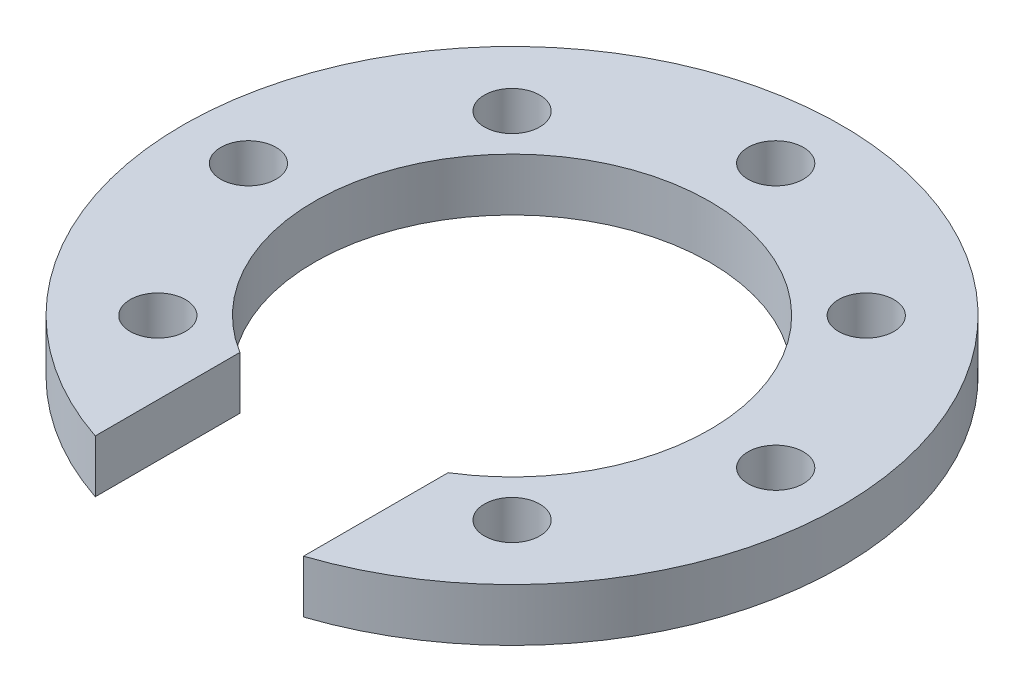
from build123d import *

# Parameters (mm, degrees)
SKETCH1_R           = 12.5
SKETCH1_R_2         = 7.5
BOSS_EXTRUDE1_DEPTH = 2
SKETCH2_R           = 1.05
CUT_EXTRUDE1_DEPTH  = 5
CIRPATTERN1_COUNT   = 3
CIRPATTERN1_ANGLE   = 180
SKETCH3_R           = 1.05
CUT_EXTRUDE2_DEPTH  = 2
SKETCH4_W           = 7.9
SKETCH4_H           = 11.346310676
CUT_EXTRUDE3_DEPTH  = 10


with BuildPart() as part:
    # Sketch1 → Boss-Extrude1 (new body)
    with BuildSketch(Plane(origin=(0, 0, 0), x_dir=(1, 0, 0), z_dir=(0, 1, 0))):
        Circle(SKETCH1_R)
        Circle(SKETCH1_R_2, mode=Mode.SUBTRACT)
    extrude(amount=BOSS_EXTRUDE1_DEPTH)

    # Sketch2 → Cut-Extrude1 (cut)
    with BuildSketch(Plane(origin=(0, 2, 0), x_dir=(1, 0, 0), z_dir=(0, 1, 0))):
        with Locations((10, 0)):
            Circle(SKETCH2_R)
    cut_extrude1 = extrude(amount=-CUT_EXTRUDE1_DEPTH, mode=Mode.SUBTRACT)

    # CirPattern1: Cut-Extrude1 ×3 about axis
    cirpattern1_axis = Axis((0, 0, 0), (0, 1, 0))
    for i in range(1, CIRPATTERN1_COUNT):
        add(cut_extrude1.rotate(cirpattern1_axis, i * CIRPATTERN1_ANGLE / (CIRPATTERN1_COUNT - 1)), mode=Mode.SUBTRACT)

    # Sketch3 → Cut-Extrude2 (cut)
    with BuildSketch(Plane(origin=(0, 2, 0), x_dir=(1, 0, 0), z_dir=(0, 1, 0))):
        with Locations((-6.71751442, 6.71751442)):
            Circle(SKETCH3_R)
        with Locations((6.71751442, 6.71751442)):
            Circle(SKETCH3_R)
        with Locations((6.71751442, -6.71751442)):
            Circle(SKETCH3_R)
        with Locations((-6.71751442, -6.71751442)):
            Circle(SKETCH3_R)
    extrude(amount=-CUT_EXTRUDE2_DEPTH, mode=Mode.SUBTRACT)

    # Sketch4 → Cut-Extrude3 (cut)
    with BuildSketch(Plane(origin=(0, 2, 0), x_dir=(1, 0, 0), z_dir=(0, 1, 0))):
        with Locations((0, -10.263253748)):
            Rectangle(SKETCH4_W, SKETCH4_H)
    extrude(amount=-CUT_EXTRUDE3_DEPTH, mode=Mode.SUBTRACT)


solid = part.part
